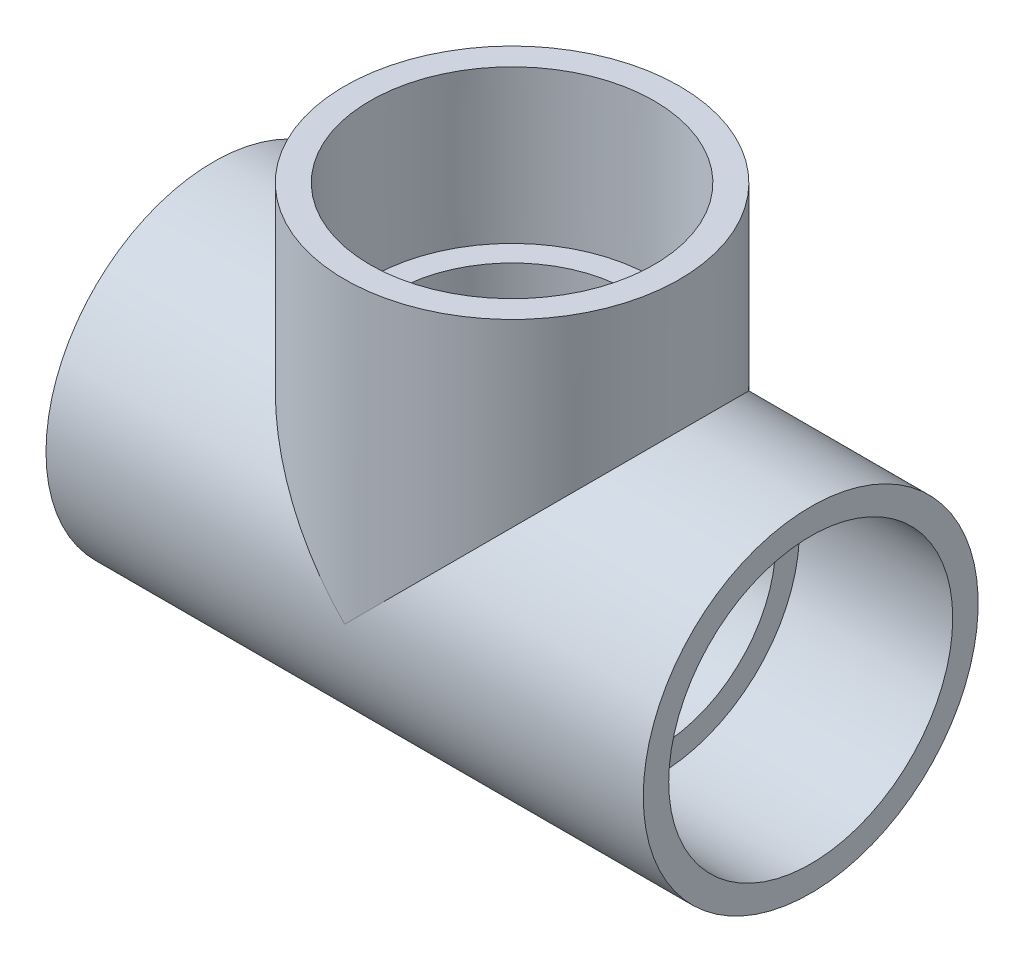
from build123d import *

# Parameters (mm, degrees)
BOSS_EXTRUDE1_DEPTH = 92.0496
BOSS_EXTRUDE2_REACH = 100.679
SKETCH5_R           = 36.83
CUT_EXTRUDE1_DEPTH  = 92.0496
CUT_EXTRUDE2_START  = -46.0248
SKETCH6_R           = 36.83
CUT_EXTRUDE2_DEPTH  = 46.0248


with BuildPart() as part:
    # Sketch1 → Revolve1 (revolve)
    with BuildSketch(Plane.XY):
        Polygon((-93.9038, -52.6542), (-46.0248, -52.6542), (-46.0248, -44.3484), (-93.9038, -44.6532), align=None)
    revolve(axis=Axis((-93.9038, 0, 0), (1, 0, 0)))


with BuildPart() as body_2:
    # Mirror1: mirrored copy
    add(part.part.mirror(Plane(origin=(0, 0, 0), x_dir=(0, 0, 1), z_dir=(1, 0, 0))))


with BuildPart() as body_3:
    # Sketch2 → Revolve2 (revolve)
    with BuildSketch(Plane.XY):
        Polygon((44.6532, 93.9038), (44.3484, 46.0248), (52.6542, 46.0248), (52.6542, 93.9038), align=None)
    revolve(axis=Axis((0, 0, 0), (0, 1, 0)))


with BuildPart() as part_1:
    add(part.part)

    add(body_2.part)  # Boss-Extrude1 merges body 2

    add(body_3.part)  # Boss-Extrude1 merges body 3
    # Sketch3 → Boss-Extrude1 (add)
    with BuildSketch(Plane(origin=(-46.0248, 0, 0), x_dir=(0, 0, -1), z_dir=(1, 0, 0))):
        with BuildLine():
            Line((25.576993, 46.0248), (-25.576993, 46.0248))
            ThreePointArc((-25.576993, 46.0248), (0, -52.6542), (25.576993, 46.0248))
        make_face()
    extrude(amount=BOSS_EXTRUDE1_DEPTH)

    # Sketch4 → Boss-Extrude2 (add, up to next)
    with BuildSketch(Plane.XZ.offset(-46.0248), mode=Mode.PRIVATE) as boss_extrude2_sk1:
        with BuildLine():
            ThreePointArc((-46.0248, -25.576993), (0, -52.6542), (46.0248, -25.576993))
            Line((46.0248, -25.576993), (-46.0248, -25.576993))
        make_face()
    boss_extrude2_tool1 = extrude(boss_extrude2_sk1.sketch, amount=BOSS_EXTRUDE2_REACH, mode=Mode.PRIVATE) - part_1.part
    add(boss_extrude2_tool1.solids().sort_by_distance((0, 46.0248, -36.688878))[0])
    # Sketch4 → Boss-Extrude2 (add, up to next)
    with BuildSketch(Plane.XZ.offset(-46.0248), mode=Mode.PRIVATE) as boss_extrude2_sk2:
        with BuildLine():
            ThreePointArc((46.0248, 25.576993), (0, 52.6542), (-46.0248, 25.576993))
            Line((-46.0248, 25.576993), (46.0248, 25.576993))
        make_face()
    boss_extrude2_tool2 = extrude(boss_extrude2_sk2.sketch, amount=BOSS_EXTRUDE2_REACH, mode=Mode.PRIVATE) - part_1.part
    add(boss_extrude2_tool2.solids().sort_by_distance((0, 46.0248, 36.688878))[0])

    # Sketch5 → Cut-Extrude1 (cut)
    with BuildSketch(Plane.ZY.offset(46.0248)):
        Circle(SKETCH5_R)
    extrude(amount=-CUT_EXTRUDE1_DEPTH, mode=Mode.SUBTRACT)

    # Sketch6 → Cut-Extrude2 (cut)
    with BuildSketch(Plane(origin=(0, 46.0248, 0), x_dir=(1, 0, 0), z_dir=(0, 1, 0)).offset(CUT_EXTRUDE2_START)):
        Circle(SKETCH6_R)
    extrude(amount=CUT_EXTRUDE2_DEPTH, mode=Mode.SUBTRACT)


solid = part_1.part
